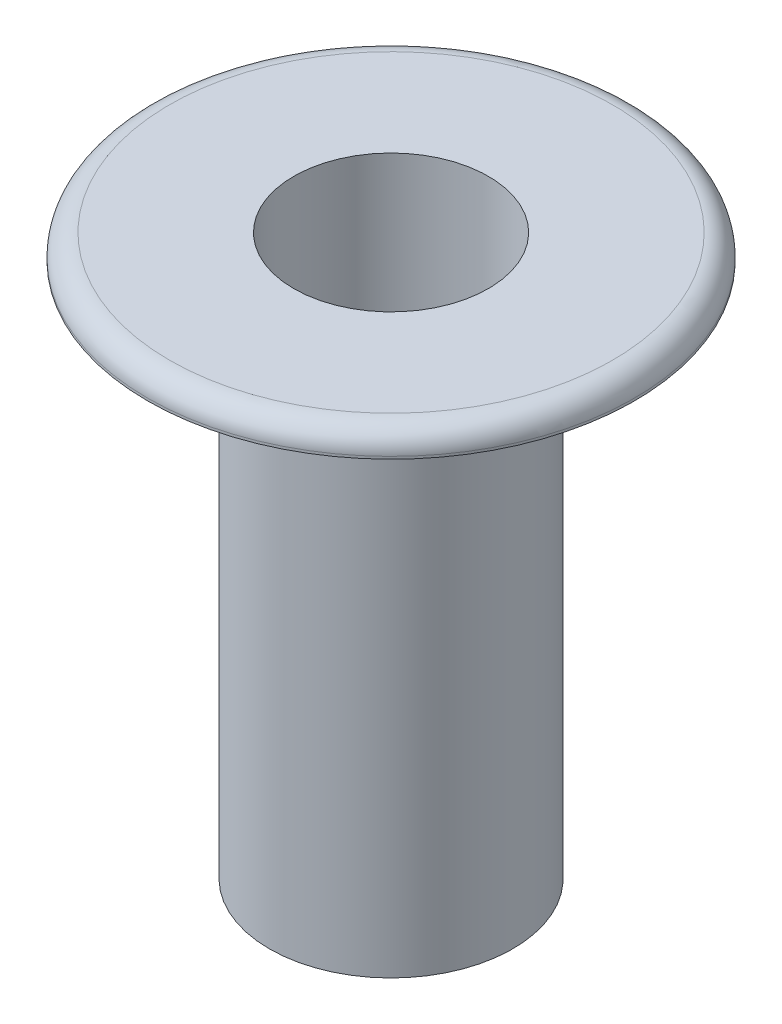
from build123d import *

# Parameters (mm, degrees)
SKETCH1_R           = 1.25
SKETCH1_R_2         = 1
BOSS_EXTRUDE1_DEPTH = 5.5
SKETCH2_R           = 2.5
SKETCH2_R_2         = 1
BOSS_EXTRUDE2_DEPTH = 0.25
FILLET1_R           = 0.225


with BuildPart() as part:
    # Sketch1 → Boss-Extrude1 (new body)
    with BuildSketch(Plane(origin=(0, 0, 0), x_dir=(1, 0, 0), z_dir=(0, 1, 0))):
        Circle(SKETCH1_R)
        Circle(SKETCH1_R_2, mode=Mode.SUBTRACT)
    extrude(amount=BOSS_EXTRUDE1_DEPTH)

    # Sketch2 → Boss-Extrude2 (add)
    with BuildSketch(Plane(origin=(0, 5.5, 0), x_dir=(1, 0, 0), z_dir=(0, 1, 0))):
        Circle(SKETCH2_R)
        Circle(SKETCH2_R_2, mode=Mode.SUBTRACT)
    extrude(amount=BOSS_EXTRUDE2_DEPTH)

    # Fillet1
    fillet1_edges = [part.edges().sort_by_distance(p)[0] for p in [
        (-2.5, 5.75, 0),
    ]]
    fillet(fillet1_edges, radius=FILLET1_R)


solid = part.part
